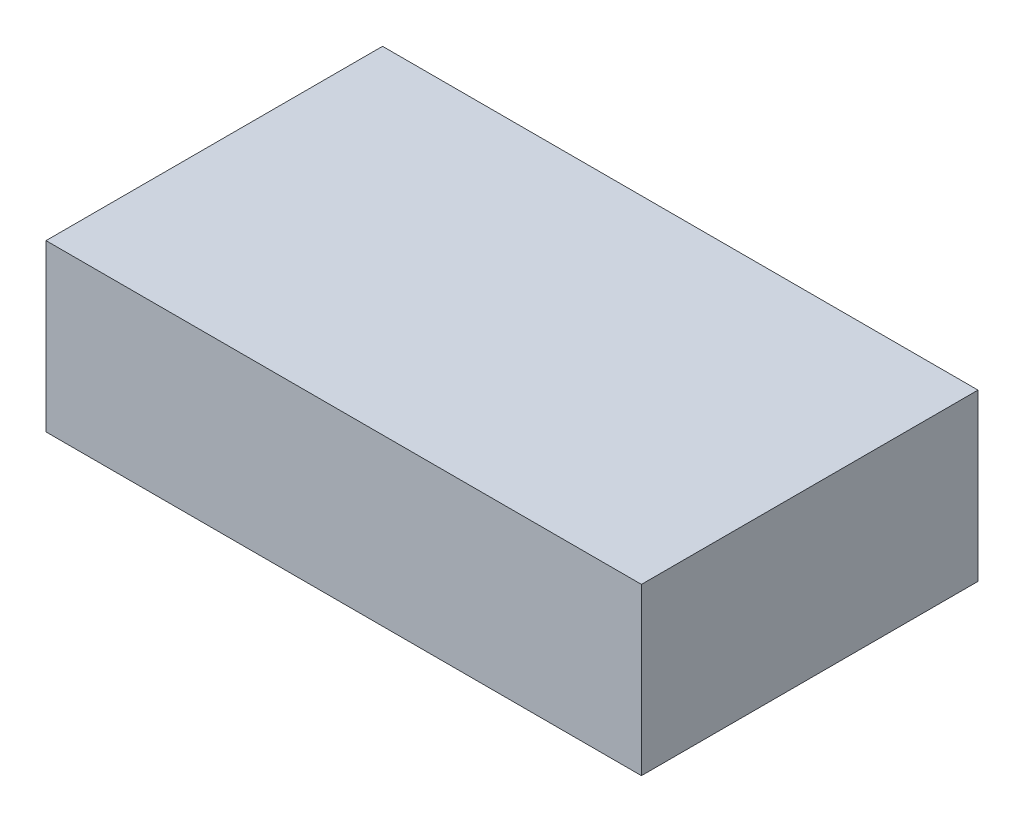
from build123d import *

# Parameters (mm, degrees)
SKETCH1_W           = 115
SKETCH1_H           = 65
BOSS_EXTRUDE1_DEPTH = 32


with BuildPart() as part:
    # Sketch1 → Boss-Extrude1 (new body)
    with BuildSketch(Plane(origin=(0, 0, 0), x_dir=(1, 0, 0), z_dir=(0, 1, 0))):
        with Locations((1.568269561, 10.225966247)):
            Rectangle(SKETCH1_W, SKETCH1_H)
    extrude(amount=BOSS_EXTRUDE1_DEPTH)


solid = part.part
